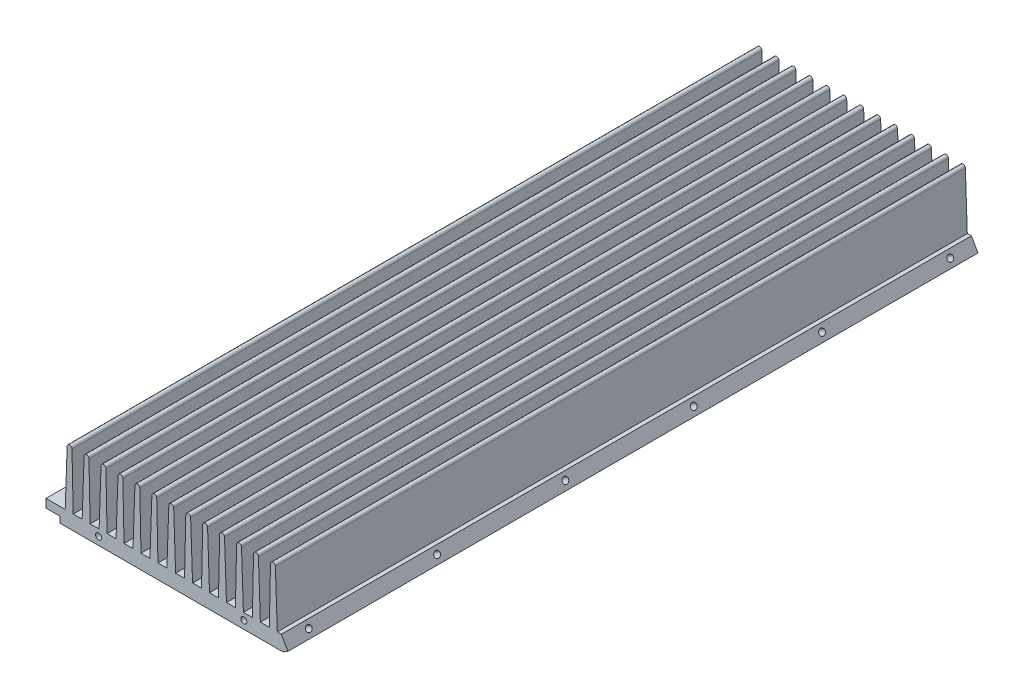
from build123d import *

# Parameters (mm, degrees)
RESSALTO_EXTRUS_O1_DEPTH   = 285
CORTE_EXTRUS_O1_DEPTH      = 1
CORTE_EXTRUS_O1_DEPTH_BACK = 286
ESBO_O4_R                  = 1.25
CORTE_EXTRUS_O3_DEPTH      = 10
ESBO_O7_R                  = 1.65
ESBO_O7_R_2                = 1.25
CORTE_EXTRUS_O5_DEPTH      = 4
ESBO_O13_R                 = 1.75
CORTE_EXTRUS_O8_DEPTH      = 3.5
CORTE_EXTRUS_O8_DEPTH_BACK = 28.5
ESBO_O14_R                 = 1.25
CORTE_EXTRUS_O9_DEPTH      = 5


with BuildPart() as part:
    # Esboço1 → Ressalto-extrusão1 (new body)
    with BuildSketch(Plane.XY):
        with BuildLine():
            Line((0, 0), (-113, 0))
            Line((-113, 0), (-113, 30))
            Line((-113, 30), (-111, 30))
            Line((-111, 30), (-111, 6))
            Line((-111, 6), (-107.3, 6))
            Line((-107.3, 6), (-106.5, 29))
            ThreePointArc((-106.5, 29), (-105.5, 30), (-104.5, 29))
            Line((-104.5, 29), (-104, 6))
            Line((-104, 6), (-100.3, 6))
            Line((-100.3, 6), (-99.5, 29))
            ThreePointArc((-99.5, 29), (-98.5, 30), (-97.5, 29))
            Line((-97.5, 29), (-97, 6))
            Line((-97, 6), (-93.3, 6))
            Line((-93.3, 6), (-92.5, 29))
            ThreePointArc((-92.5, 29), (-91.5, 30), (-90.5, 29))
            Line((-90.5, 29), (-90, 6))
            Line((-90, 6), (-86.3, 6))
            Line((-86.3, 6), (-85.5, 29))
            ThreePointArc((-85.5, 29), (-84.5, 30), (-83.5, 29))
            Line((-83.5, 29), (-83, 6))
            Line((-83, 6), (-79.3, 6))
            Line((-79.3, 6), (-78.5, 29))
            ThreePointArc((-78.5, 29), (-77.5, 30), (-76.5, 29))
            Line((-76.5, 29), (-76, 6))
            Line((-76, 6), (-72.3, 6))
            Line((-72.3, 6), (-71.5, 29))
            ThreePointArc((-71.5, 29), (-70.5, 30), (-69.5, 29))
            Line((-69.5, 29), (-69, 6))
            Line((-69, 6), (-65.3, 6))
            Line((-65.3, 6), (-64.5, 29))
            ThreePointArc((-64.5, 29), (-63.5, 30), (-62.5, 29))
            Line((-62.5, 29), (-62, 6))
            Line((-62, 6), (-58.3, 6))
            Line((-58.3, 6), (-57.5, 29))
            ThreePointArc((-57.5, 29), (-56.5, 30), (-55.5, 29))
            Line((-55.5, 29), (-54.7, 6))
            Line((-54.7, 6), (-51, 6))
            Line((-51, 6), (-50.5, 29))
            ThreePointArc((-50.5, 29), (-49.5, 30), (-48.5, 29))
            Line((-48.5, 29), (-47.7, 6))
            Line((-47.7, 6), (-44, 6))
            Line((-44, 6), (-43.5, 29))
            ThreePointArc((-43.5, 29), (-42.5, 30), (-41.5, 29))
            Line((-41.5, 29), (-40.7, 6))
            Line((-40.7, 6), (-37, 6))
            Line((-37, 6), (-36.5, 29))
            ThreePointArc((-36.5, 29), (-35.5, 30), (-34.5, 29))
            Line((-34.5, 29), (-33.7, 6))
            Line((-33.7, 6), (-30, 6))
            Line((-30, 6), (-29.5, 29))
            ThreePointArc((-29.5, 29), (-28.5, 30), (-27.5, 29))
            Line((-27.5, 29), (-26.7, 6))
            Line((-26.7, 6), (-23, 6))
            Line((-23, 6), (-22.5, 29))
            ThreePointArc((-22.5, 29), (-21.5, 30), (-20.5, 29))
            Line((-20.5, 29), (-19.7, 6))
            Line((-19.7, 6), (-16, 6))
            Line((-16, 6), (-15.5, 29))
            ThreePointArc((-15.5, 29), (-14.5, 30), (-13.5, 29))
            Line((-13.5, 29), (-12.7, 6))
            Line((-12.7, 6), (-9, 6))
            Line((-9, 6), (-8.5, 29))
            ThreePointArc((-8.5, 29), (-7.5, 30), (-6.5, 29))
            Line((-6.5, 29), (-5.7, 6))
            Line((-5.7, 6), (-2, 6))
            Line((-2, 6), (-2, 30))
            Line((-2, 30), (0, 30))
            Line((0, 30), (0, 0))
        make_face()
    extrude(amount=RESSALTO_EXTRUS_O1_DEPTH)

    # Esboço2 → Corte-extrusão1 (cut, two sides)
    with BuildSketch(Plane.XY.offset(285)) as corte_extrus_o1_sk:
        Polygon((-102.890485004, 6), (-108.234061138, 6), (-108.234061138, 2.5), (-102.553847577, 2.5), (-102.553847577, 0), (-107.964469124, -3.436706701), (-125.556799279, -3.436706701), (-125.556799279, 31.540588642), (-102.890485004, 31.540588642), align=None)
        Polygon((-8.281088913, 1.25), (-10.446152423, 0), (0, 0), (0, 38.558769493), (-11.416815759, 38.558769493), (-11.416815759, 6.681238216), align=None)
    extrude(amount=CORTE_EXTRUS_O1_DEPTH, mode=Mode.SUBTRACT)
    extrude(corte_extrus_o1_sk.sketch, amount=-CORTE_EXTRUS_O1_DEPTH_BACK, mode=Mode.SUBTRACT)

    # Esboço4 → Corte-extrusão3 (cut)
    with BuildSketch(Plane.XY.offset(285)):
        with Locations((-26.5, 3.234792224)):
            Circle(ESBO_O4_R)
        with Locations((-86.5, 3.234792224)):
            Circle(ESBO_O4_R)
    extrude(amount=-CORTE_EXTRUS_O3_DEPTH, mode=Mode.SUBTRACT)

    # Esboço7 → Corte-extrusão5 (cut)
    with BuildSketch(Plane(origin=(0, 0, 0), x_dir=(-1, 0, 0), z_dir=(0, -1, 0))):
        with Locations((95, -28.5)):
            Circle(ESBO_O7_R)
        with Locations((71.949, -28.592)):
            Circle(ESBO_O7_R_2)
        with Locations((72.33, -10.685)):
            Circle(ESBO_O7_R_2)
        with Locations((30.928, -51.5)):
            Circle(ESBO_O7_R_2)
        with Locations((24, -15)):
            Circle(ESBO_O7_R)
        with Locations((34.738, -79.011)):
            Circle(ESBO_O7_R_2)
        with Locations((18.355, -144.416)):
            Circle(ESBO_O7_R)
        with Locations((20, -249)):
            Circle(ESBO_O7_R)
        with Locations((35.246, -237)):
            Circle(ESBO_O7_R_2)
        with Locations((93, -249)):
            Circle(ESBO_O7_R)
        with Locations((78.807, -182.77)):
            Circle(ESBO_O7_R_2)
        with Locations((82.363, -100.093)):
            Circle(ESBO_O7_R_2)
        with Locations((29.404, -176.293)):
            Circle(ESBO_O7_R_2)
        with Locations((38.999998474, -219.999999573)):
            Circle(ESBO_O7_R_2)
        with Locations((38.999998474, -199.999999573)):
            Circle(ESBO_O7_R_2)
        with Locations((38.999998474, -179.999999573)):
            Circle(ESBO_O7_R_2)
        with Locations((38.999998474, -159.999999573)):
            Circle(ESBO_O7_R_2)
        with Locations((73.999998474, -129.999991943)):
            Circle(ESBO_O7_R_2)
        with Locations((73.999998474, -110.000007202)):
            Circle(ESBO_O7_R_2)
        with Locations((73.999998474, -90.000007202)):
            Circle(ESBO_O7_R_2)
        with Locations((73.999998474, -69.999991943)):
            Circle(ESBO_O7_R_2)
        with Locations((92.737766412, -168.347796909)):
            Circle(ESBO_O7_R_2)
        with Locations((94.207008215, -195.602168929)):
            Circle(ESBO_O7_R_2)
        with Locations((89.504149751, -51.5)):
            Circle(ESBO_O7_R_2)
        with Locations((49.75, -279)):
            Circle(ESBO_O7_R_2)
        with Locations((63.25, -279)):
            Circle(ESBO_O7_R_2)
    extrude(amount=-CORTE_EXTRUS_O5_DEPTH, mode=Mode.SUBTRACT)

    # Esboço13 → Corte-extrusão8 (cut, two sides)
    with BuildSketch(Plane.XZ.offset(-2.5)) as corte_extrus_o8_sk:
        with Locations((-105.393954358, 275)):
            Circle(ESBO_O13_R)
        with Locations((-105.393954358, 222)):
            Circle(ESBO_O13_R)
        with Locations((-105.393954358, 169)):
            Circle(ESBO_O13_R)
        with Locations((-105.393954358, 63)):
            Circle(ESBO_O13_R)
        with Locations((-105.393954358, 10)):
            Circle(ESBO_O13_R)
        with Locations((-105.393954358, 116)):
            Circle(ESBO_O13_R)
    extrude(amount=CORTE_EXTRUS_O8_DEPTH, mode=Mode.SUBTRACT)
    extrude(corte_extrus_o8_sk.sketch, amount=-CORTE_EXTRUS_O8_DEPTH_BACK, mode=Mode.SUBTRACT)

    # Esboço14 → Corte-extrusão9 (cut)
    with BuildSketch(Plane(origin=(-5.669550808, -3.273316685, 0), x_dir=(0, 0, -1), z_dir=(0.866025404, 0.5, 0))):
        with Locations((-275, 8.063182992)):
            Circle(ESBO_O14_R)
        with Locations((-222, 8.063182992)):
            Circle(ESBO_O14_R)
        with Locations((-169, 8.063182992)):
            Circle(ESBO_O14_R)
        with Locations((-116, 8.063182992)):
            Circle(ESBO_O14_R)
        with Locations((-63, 8.063182992)):
            Circle(ESBO_O14_R)
        with Locations((-10, 8.063182992)):
            Circle(ESBO_O14_R)
    extrude(amount=-CORTE_EXTRUS_O9_DEPTH, mode=Mode.SUBTRACT)


solid = part.part
